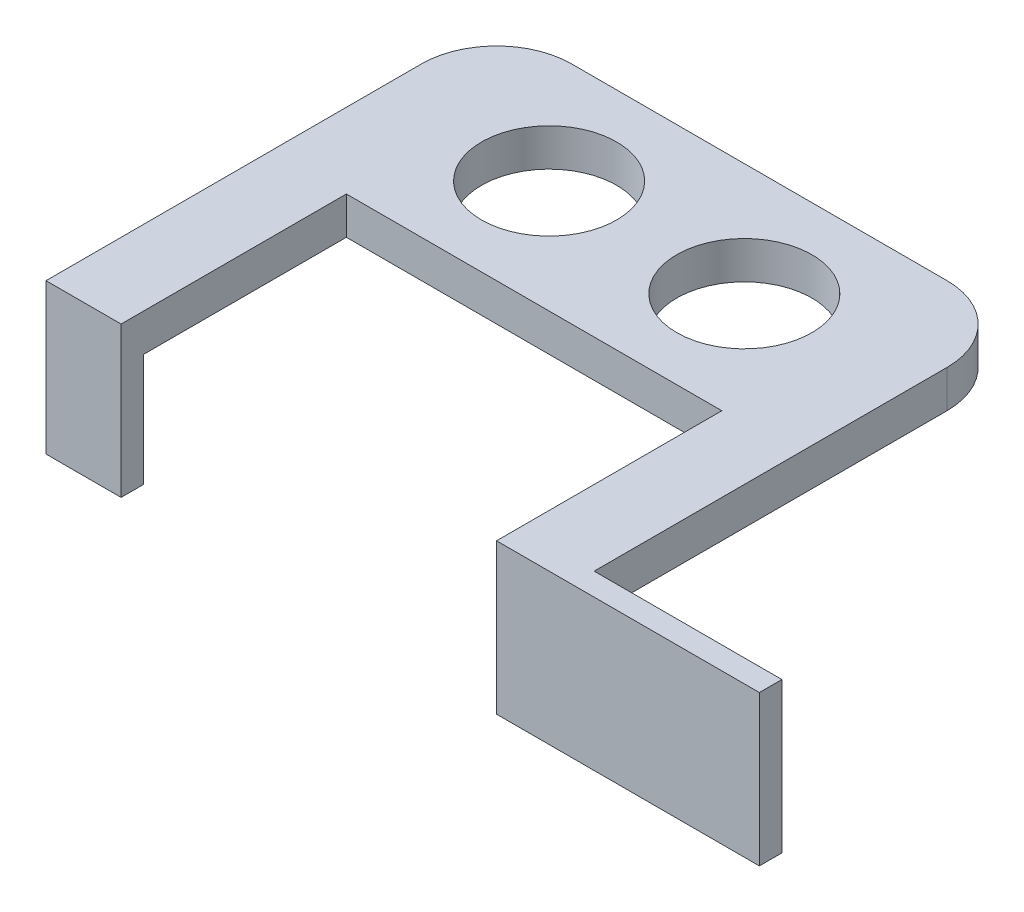
from build123d import *

# Parameters (mm, degrees)
ESQUISSE3_R        = 9
BOSS_EXTRU_1_DEPTH = 5
ESQUISSE4_W        = 10
ESQUISSE4_H        = 3
ESQUISSE4_W_2      = 35
BOSS_EXTRU_2_DEPTH = 20


with BuildPart() as part:
    # Esquisse3 → Boss.-Extru.1 (new body)
    with BuildSketch(Plane(origin=(0, 0, 0), x_dir=(1, 0, 0), z_dir=(0, 1, 0))):
        with BuildLine():
            Line((-42.049920388, -18.295081967), (-42.049920388, 31.704918033))
            ThreePointArc((-42.049920388, 31.704918033), (-39.120988199, 38.775985845), (-32.049920388, 41.704918033))
            Line((-32.049920388, 41.704918033), (17.950079612, 41.704918033))
            ThreePointArc((17.950079612, 41.704918033), (25.021147424, 38.775985845), (27.950079612, 31.704918033))
            Line((27.950079612, 31.704918033), (27.950079612, -15.295081967))
            Line((27.950079612, -15.295081967), (52.950079612, -15.295081967))
            Line((52.950079612, -15.295081967), (52.950079612, -18.295081967))
            Line((52.950079612, -18.295081967), (17.950079612, -18.295081967))
            Line((17.950079612, -18.295081967), (17.950079612, 11.704918033))
            Line((17.950079612, 11.704918033), (-32.049920388, 11.704918033))
            Line((-32.049920388, 11.704918033), (-32.049920388, -18.295081967))
            Line((-32.049920388, -18.295081967), (-42.049920388, -18.295081967))
        make_face()
        with Locations((-20.049920388, 26.704918033)):
            Circle(ESQUISSE3_R, mode=Mode.SUBTRACT)
        with Locations((5.950079612, 26.704918033)):
            Circle(ESQUISSE3_R, mode=Mode.SUBTRACT)
    extrude(amount=BOSS_EXTRU_1_DEPTH)

    # Esquisse4 → Boss.-Extru.2 (add)
    with BuildSketch(Plane(origin=(0, 5, 0), x_dir=(1, 0, 0), z_dir=(0, 1, 0))):
        with Locations((-37.049920388, -16.795081967)):
            Rectangle(ESQUISSE4_W, ESQUISSE4_H)
        with Locations((35.450079612, -16.795081967)):
            Rectangle(ESQUISSE4_W_2, ESQUISSE4_H)
    extrude(amount=-BOSS_EXTRU_2_DEPTH)


solid = part.part
